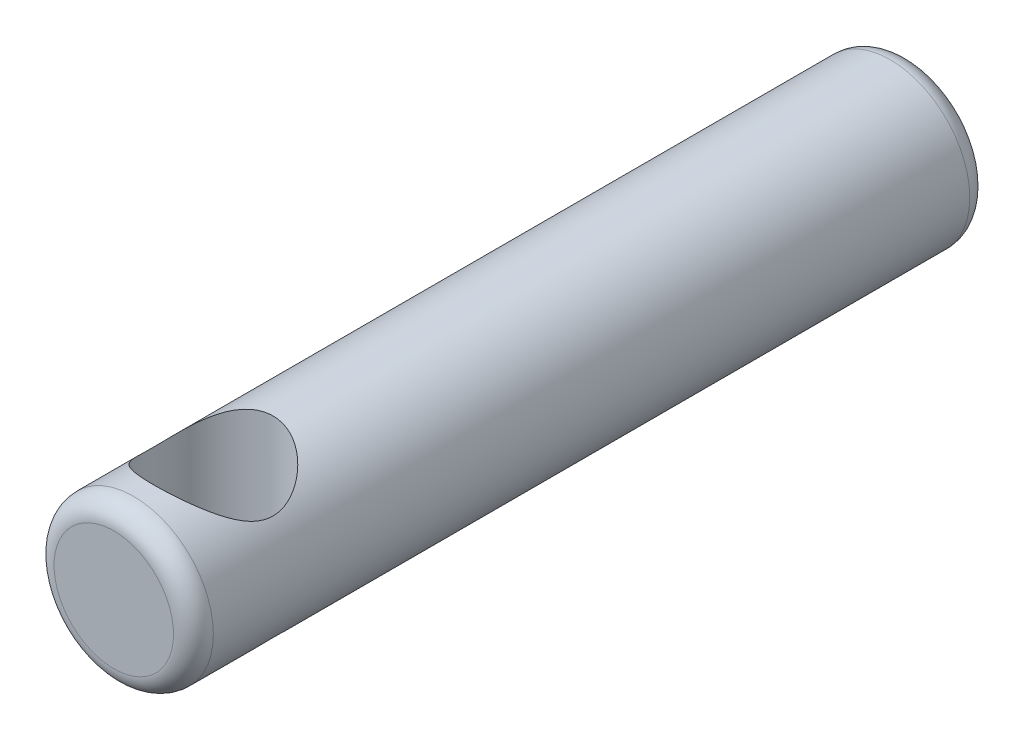
from build123d import *

# Parameters (mm, degrees)
SKETCH1_R               = 2
BOSS_EXTRUDE1_DEPTH     = 20
SKETCH2_R               = 1.5
CUT_EXTRUDE1_DEPTH      = 3
CUT_EXTRUDE1_DEPTH_BACK = 3
FILLET1_R               = 0.5


with BuildPart() as part:
    # Sketch1 → Boss-Extrude1 (new body)
    with BuildSketch(Plane.XY):
        Circle(SKETCH1_R)
    extrude(amount=BOSS_EXTRUDE1_DEPTH)

    # Sketch2 → Cut-Extrude1 (cut, two sides)
    with BuildSketch(Plane(origin=(0, 0, 0), x_dir=(1, 0, 0), z_dir=(0, 1, 0))) as cut_extrude1_sk:
        with Locations((0, -17.5)):
            Circle(SKETCH2_R)
    extrude(amount=CUT_EXTRUDE1_DEPTH, mode=Mode.SUBTRACT)
    extrude(cut_extrude1_sk.sketch, amount=-CUT_EXTRUDE1_DEPTH_BACK, mode=Mode.SUBTRACT)

    # Fillet1
    fillet1_edges = [part.edges().sort_by_distance(p)[0] for p in [
        (-2, 0, 0),
        (-2, 0, 20),
    ]]
    fillet(fillet1_edges, radius=FILLET1_R)


solid = part.part
